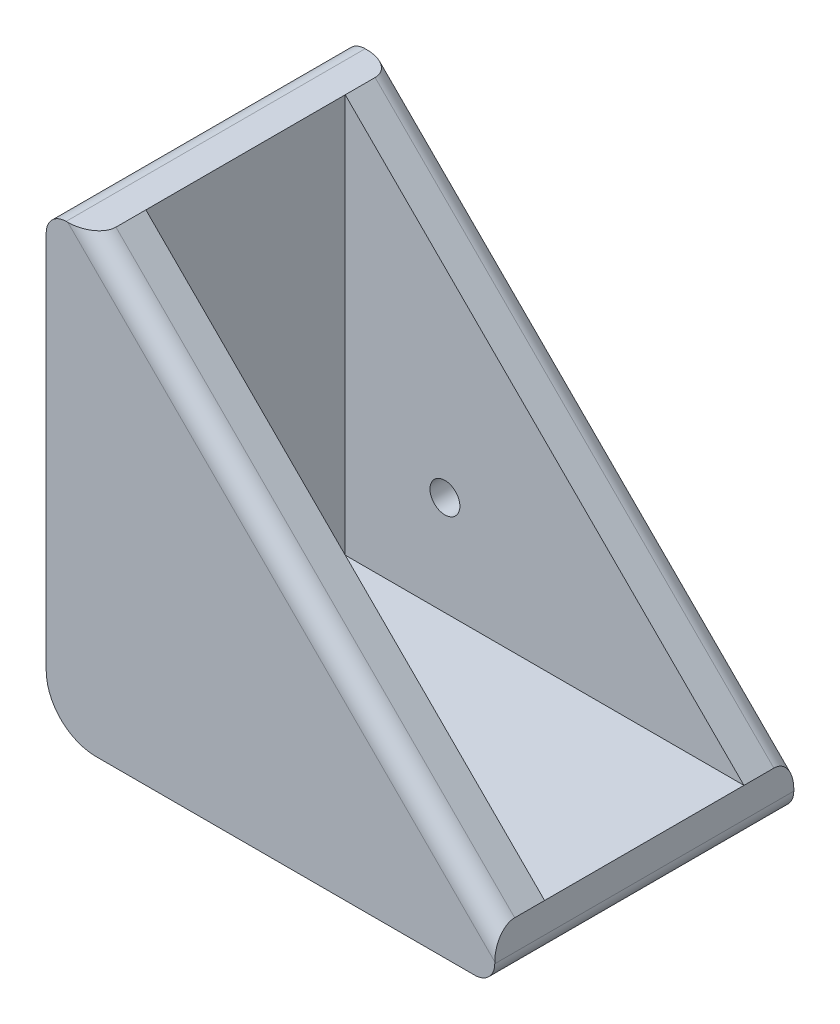
from build123d import *

# Parameters (mm, degrees)
BOSS_EXTRUDE2_DEPTH = 30
BOSS_EXTRUDE3_DEPTH = 5
BOSS_EXTRUDE4_DEPTH = 5
SKETCH4_R           = 1.5
CUT_EXTRUDE1_DEPTH  = 46
SKETCH5_R           = 1.5
CUT_EXTRUDE2_DEPTH  = 6
FILLET1_R           = 2
FILLET2_R           = 5


with BuildPart() as part:
    # Sketch1 → Boss-Extrude2 (new body)
    with BuildSketch(Plane.XY):
        Polygon((0, 0), (0, 45), (5, 45), (5, 5), (45, 5), (45, 0), align=None)
    extrude(amount=BOSS_EXTRUDE2_DEPTH)

    # Sketch2 → Boss-Extrude3 (add)
    with BuildSketch(Plane.XY.offset(30)):
        Polygon((5, 45), (45, 5), (5, 5), align=None)
    extrude(amount=-BOSS_EXTRUDE3_DEPTH)

    # Sketch3 → Boss-Extrude4 (add)
    with BuildSketch(Plane(origin=(0, 0, 0), x_dir=(-1, 0, 0), z_dir=(0, 0, -1))):
        Polygon((-5, 45), (-5, 5), (-45, 5), align=None)
    extrude(amount=-BOSS_EXTRUDE4_DEPTH)

    # Sketch4 → Cut-Extrude1 (cut, through all)
    with BuildSketch(Plane.XZ):
        with Locations((15, 15)):
            Circle(SKETCH4_R)
    extrude(amount=-CUT_EXTRUDE1_DEPTH, mode=Mode.SUBTRACT)

    # Sketch5 → Cut-Extrude2 (cut, through all)
    with BuildSketch(Plane.XY.offset(5)):
        with Locations((15, 15)):
            Circle(SKETCH5_R)
    extrude(amount=-CUT_EXTRUDE2_DEPTH, mode=Mode.SUBTRACT)

    # Fillet1
    fillet1_edges = [part.edges().sort_by_distance(p)[0] for p in [
        (0, 45, 15),
        (45, 0, 15),
        (25, 25, 30),
        (25, 25, 0),
    ]]
    fillet(fillet1_edges, radius=FILLET1_R)

    # Fillet2
    fillet2_edges = [part.edges().sort_by_distance(p)[0] for p in [
        (0, 0, 15),
    ]]
    fillet(fillet2_edges, radius=FILLET2_R)


solid = part.part
